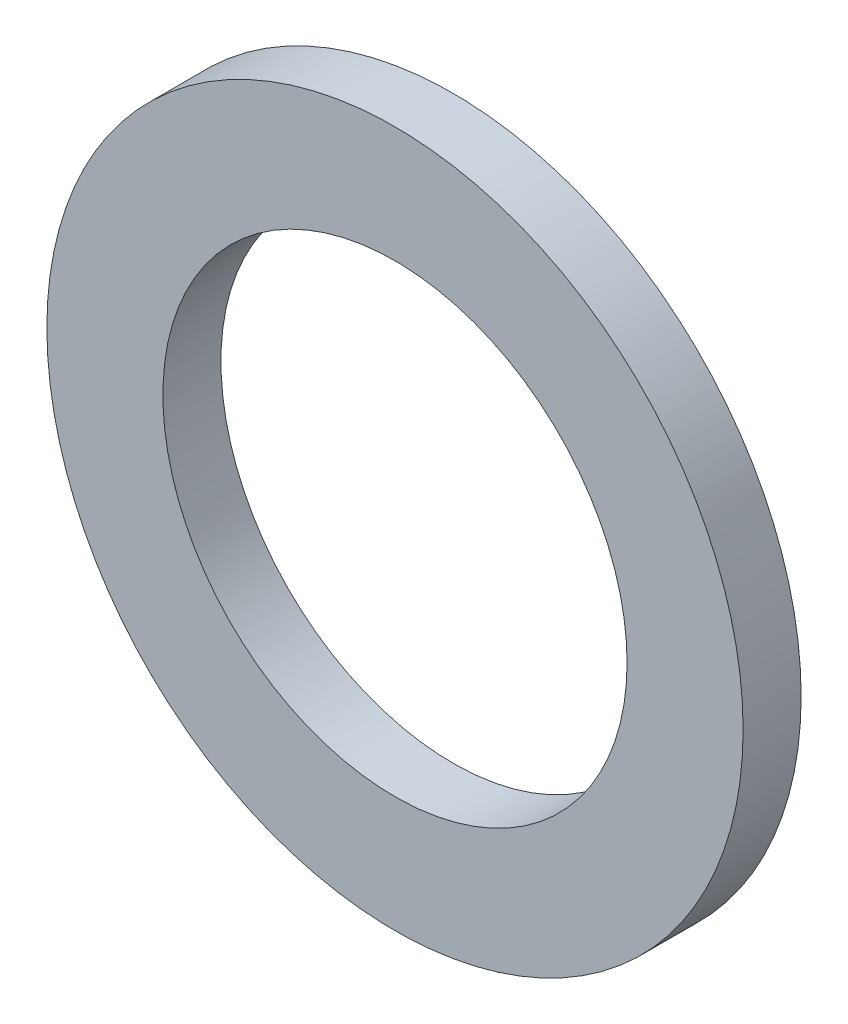
from build123d import *

# Parameters (mm, degrees)
SKETCH_1_R      = 9
SKETCH_1_R_2    = 6
EXTRUDE_1_DEPTH = 1.5


with BuildPart() as part:
    # Эскиз1 → Бобышка-Вытянуть1 (new body)
    with BuildSketch(Plane.XY):
        Circle(SKETCH_1_R)
        Circle(SKETCH_1_R_2, mode=Mode.SUBTRACT)
    extrude(amount=EXTRUDE_1_DEPTH)


solid = part.part
